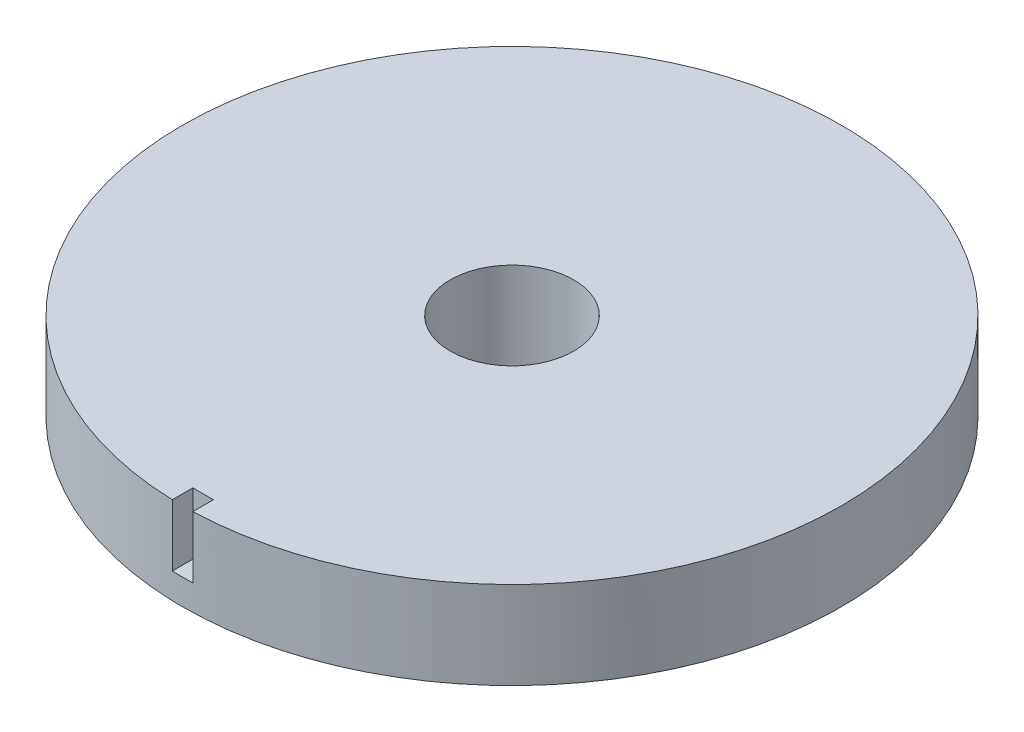
from build123d import *

# Parameters (mm, degrees)
SKETCH1_R                 = 16
SKETCH1_R_2               = 3
BOSS_EXTRUDE1_DEPTH       = 4.25
CUT_EXTRUDE1_REACH        = 26.023
CUT_EXTRUDE1_START_RADIUS = 16
CUT_EXTRUDE1_END_RADIUS   = 16
SKETCH2_W                 = 1
SKETCH2_H                 = 3


with BuildPart() as part:
    # Sketch1 → Boss-Extrude1 (new body)
    with BuildSketch(Plane(origin=(0, 0, 0), x_dir=(1, 0, 0), z_dir=(0, 1, 0))):
        with Locations(Location((0, 0, 0), (0, 0, 270))):
            Circle(SKETCH1_R)
        with Locations(Location((0, 0, 0), (0, 0, 270))):
            Circle(SKETCH1_R_2, mode=Mode.SUBTRACT)
    extrude(amount=BOSS_EXTRUDE1_DEPTH)

    # Cut-Extrude1: from a cylinder face, 26.023 long prism both ways, kept between that surface and its translate by the depth
    cut_extrude1_start = Plane(origin=(0, 2.75, 0), z_dir=(0, -1, 0)) * Cylinder(CUT_EXTRUDE1_START_RADIUS, 85.046, mode=Mode.PRIVATE)
    cut_extrude1_end = Plane(origin=(0, 2.75, -1), z_dir=(0, -1, 0)) * Cylinder(CUT_EXTRUDE1_END_RADIUS, 85.046, mode=Mode.PRIVATE)
    # Sketch2 → Cut-Extrude1 (cut, from a surface)
    with BuildSketch(Plane.XY, mode=Mode.PRIVATE) as cut_extrude1_sk1:
        with Locations((0, 2.75)):
            Rectangle(SKETCH2_W, SKETCH2_H)
    cut_extrude1_tool1 = extrude(cut_extrude1_sk1.sketch, amount=CUT_EXTRUDE1_REACH, both=True, mode=Mode.PRIVATE)
    add(((cut_extrude1_tool1 & cut_extrude1_start) - cut_extrude1_end).solids().sort_by_distance((0, 2.75, 15.492186))[0], mode=Mode.SUBTRACT)


solid = part.part
